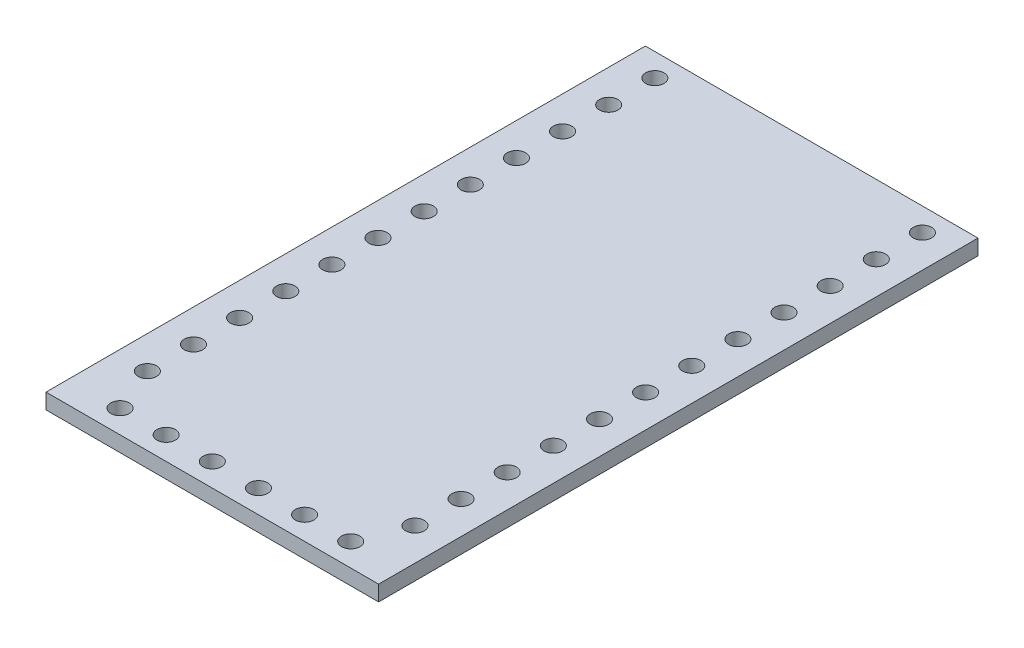
from build123d import *

# Parameters (mm, degrees)
SKETCH1_W           = 18.3134
SKETCH1_H           = 33
SKETCH1_R           = 0.508
BOSS_EXTRUDE1_DEPTH = 0.425


with BuildPart() as part:
    # Sketch1 → Boss-Extrude1 (new body, symmetric)
    with BuildSketch(Plane(origin=(0, 0, 0), x_dir=(1, 0, 0), z_dir=(0, 1, 0))):
        Rectangle(SKETCH1_W, SKETCH1_H)
        with Locations((-6.35, -15.23)):
            Circle(SKETCH1_R, mode=Mode.SUBTRACT)
        with Locations((-3.81, -15.23)):
            Circle(SKETCH1_R, mode=Mode.SUBTRACT)
        with Locations((-1.27, -15.23)):
            Circle(SKETCH1_R, mode=Mode.SUBTRACT)
        with Locations((1.27, -15.23)):
            Circle(SKETCH1_R, mode=Mode.SUBTRACT)
        with Locations((3.81, -15.23)):
            Circle(SKETCH1_R, mode=Mode.SUBTRACT)
        with Locations((6.35, -15.23)):
            Circle(SKETCH1_R, mode=Mode.SUBTRACT)
        with Locations((-7.366, 15.23)):
            Circle(SKETCH1_R, mode=Mode.SUBTRACT)
        with Locations((-7.366, 12.69)):
            Circle(SKETCH1_R, mode=Mode.SUBTRACT)
        with Locations((-7.366, 10.15)):
            Circle(SKETCH1_R, mode=Mode.SUBTRACT)
        with Locations((-7.366, 7.61)):
            Circle(SKETCH1_R, mode=Mode.SUBTRACT)
        with Locations((-7.366, 5.07)):
            Circle(SKETCH1_R, mode=Mode.SUBTRACT)
        with Locations((-7.366, 2.53)):
            Circle(SKETCH1_R, mode=Mode.SUBTRACT)
        with Locations((-7.366, -0.01)):
            Circle(SKETCH1_R, mode=Mode.SUBTRACT)
        with Locations((-7.366, -2.55)):
            Circle(SKETCH1_R, mode=Mode.SUBTRACT)
        with Locations((-7.366, -5.09)):
            Circle(SKETCH1_R, mode=Mode.SUBTRACT)
        with Locations((-7.366, -7.63)):
            Circle(SKETCH1_R, mode=Mode.SUBTRACT)
        with Locations((-7.366, -10.17)):
            Circle(SKETCH1_R, mode=Mode.SUBTRACT)
        with Locations((-7.366, -12.71)):
            Circle(SKETCH1_R, mode=Mode.SUBTRACT)
        with Locations((7.366, -12.71)):
            Circle(SKETCH1_R, mode=Mode.SUBTRACT)
        with Locations((7.366, -10.17)):
            Circle(SKETCH1_R, mode=Mode.SUBTRACT)
        with Locations((7.366, -7.63)):
            Circle(SKETCH1_R, mode=Mode.SUBTRACT)
        with Locations((7.366, -5.09)):
            Circle(SKETCH1_R, mode=Mode.SUBTRACT)
        with Locations((7.366, -2.55)):
            Circle(SKETCH1_R, mode=Mode.SUBTRACT)
        with Locations((7.366, -0.01)):
            Circle(SKETCH1_R, mode=Mode.SUBTRACT)
        with Locations((7.366, 2.53)):
            Circle(SKETCH1_R, mode=Mode.SUBTRACT)
        with Locations((7.366, 5.07)):
            Circle(SKETCH1_R, mode=Mode.SUBTRACT)
        with Locations((7.366, 7.61)):
            Circle(SKETCH1_R, mode=Mode.SUBTRACT)
        with Locations((7.366, 10.15)):
            Circle(SKETCH1_R, mode=Mode.SUBTRACT)
        with Locations((7.366, 12.69)):
            Circle(SKETCH1_R, mode=Mode.SUBTRACT)
        with Locations((7.366, 15.23)):
            Circle(SKETCH1_R, mode=Mode.SUBTRACT)
    extrude(amount=BOSS_EXTRUDE1_DEPTH, both=True)


solid = part.part
